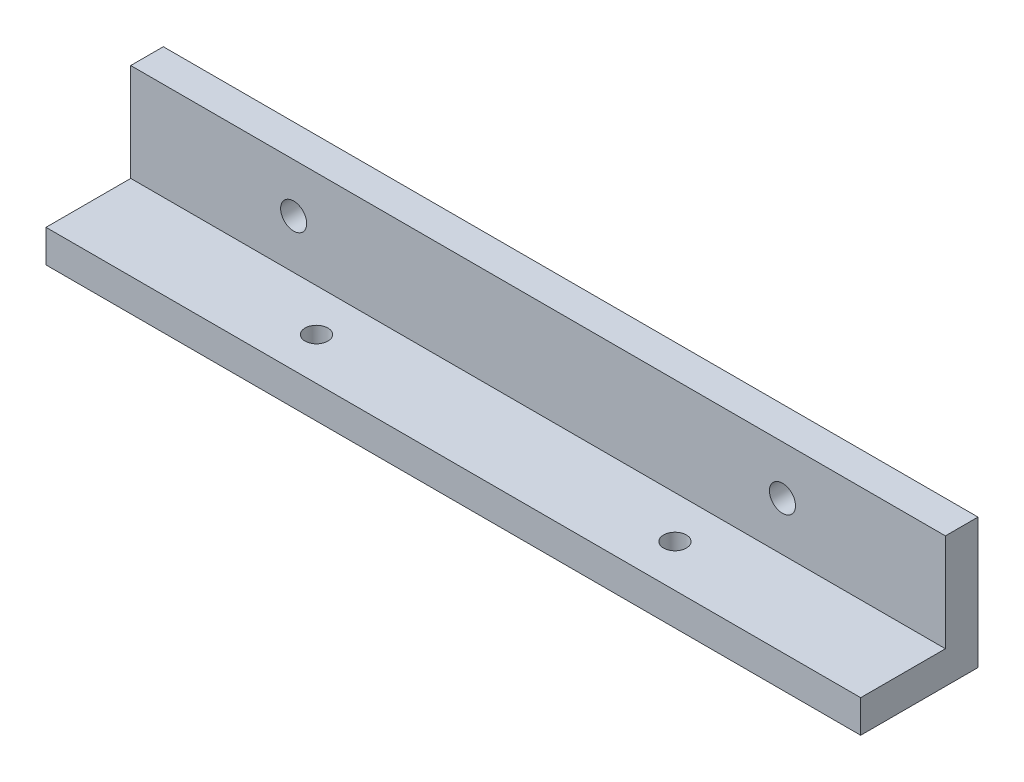
from build123d import *

# Parameters (mm, degrees)
SKETCH1_W           = 125
SKETCH1_H           = 18
BOSS_EXTRUDE1_DEPTH = 5
SKETCH3_W           = 125
SKETCH3_H           = 5
BOSS_EXTRUDE2_DEPTH = 15
SKETCH5_R           = 2
CUT_EXTRUDE1_DEPTH  = 6
SKETCH6_R           = 1.75
CUT_EXTRUDE2_DEPTH  = 6


with BuildPart() as part:
    # Sketch1 → Boss-Extrude1 (new body)
    with BuildSketch(Plane(origin=(0, 0, 0), x_dir=(1, 0, 0), z_dir=(0, 1, 0))):
        with Locations((62.5, 9)):
            Rectangle(SKETCH1_W, SKETCH1_H)
    extrude(amount=-BOSS_EXTRUDE1_DEPTH)

    # Sketch3 → Boss-Extrude2 (add)
    with BuildSketch(Plane(origin=(0, 0, 0), x_dir=(1, 0, 0), z_dir=(0, 1, 0))):
        with Locations((62.5, 15.5)):
            Rectangle(SKETCH3_W, SKETCH3_H)
    extrude(amount=BOSS_EXTRUDE2_DEPTH)

    # Sketch5 → Cut-Extrude1 (cut, through all)
    with BuildSketch(Plane.XY.offset(-13)):
        with Locations((25, 7.5)):
            Circle(SKETCH5_R)
        with Locations((100, 7.5)):
            Circle(SKETCH5_R)
    extrude(amount=-CUT_EXTRUDE1_DEPTH, mode=Mode.SUBTRACT)

    # Sketch6 → Cut-Extrude2 (cut, through all)
    with BuildSketch(Plane(origin=(0, 0, 0), x_dir=(1, 0, 0), z_dir=(0, 1, 0))):
        with Locations((35, 6.5)):
            Circle(SKETCH6_R)
        with Locations((90, 6.5)):
            Circle(SKETCH6_R)
    extrude(amount=-CUT_EXTRUDE2_DEPTH, mode=Mode.SUBTRACT)


solid = part.part
